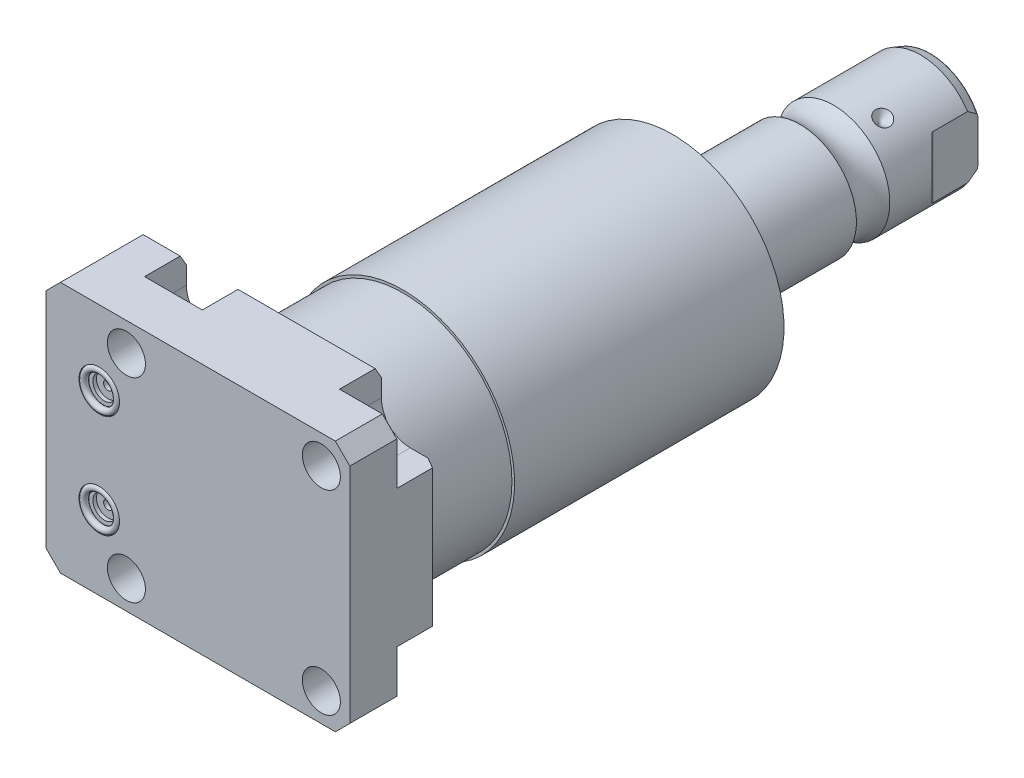
from build123d import *

# Parameters (mm, degrees)
SKETCH1_W                = 85.4964
SKETCH1_H                = 70.866
EXTRUDE1_DEPTH           = 25.019
SKETCH2_R                = 5.3594
CUT_EXTRUDE1_DEPTH       = 27.5209
LPATTERN1_COUNT          = 2
LPATTERN1_PITCH          = 54.864
LPATTERN1_COUNT_DIR2     = 2
LPATTERN1_PITCH_DIR2     = 54.864
CUT_EXTRUDE2_DEPTH       = 11.7856
SKETCH6_R                = 5.7023
CUT_EXTRUDE3_DEPTH       = 1.4478
SKETCH7_R                = 3.2512
CUT_EXTRUDE4_DEPTH       = 1.016
SKETCH8_R                = 1.2446
CUT_EXTRUDE5_DEPTH       = 11.9888
SKETCH9_R                = 0.9271
CHAMFER1_SIZE            = 4.064
CHAMFER2_SIZE            = 3.0226
CHAMFER2_SIZE2           = 1.745099
SKETCH14_R               = 31.3944
EXTRUDE2_DEPTH           = 104.5464
SKETCH15_OUTSIDE_W       = 121.686
SKETCH15_OUTSIDE_H       = 107.056
SKETCH15_OUTSIDE_R       = 30.6578
CUT_EXTRUDE9_DEPTH       = 25.4
CIRPATTERN1_COUNT        = 3
FILLET1_R                = 0.635
CUT_EXTRUDE12_DEPTH      = 36.433
CUT_EXTRUDE12_DEPTH_BACK = 36.433


with BuildPart() as part:
    # Sketch1 → Extrude1 (new body)
    with BuildSketch(Plane.XY):
        with Locations((-7.3152, 0)):
            Rectangle(SKETCH1_W, SKETCH1_H)
    extrude(amount=EXTRUDE1_DEPTH)

    # Sketch2 → Cut-Extrude1 (cut)
    with BuildSketch(Plane(origin=(0, 0, 0), x_dir=(-1, 0, 0), z_dir=(0, 0, -1))):
        with Locations((-27.432, -27.432)):
            Circle(SKETCH2_R)
    cut_extrude1 = extrude(amount=-CUT_EXTRUDE1_DEPTH, mode=Mode.SUBTRACT)

    # LPattern1: Cut-Extrude1 2 × 2
    with Locations(*[(-j * LPATTERN1_PITCH_DIR2, i * LPATTERN1_PITCH, 0) for i in range(LPATTERN1_COUNT) for j in range(LPATTERN1_COUNT_DIR2) if (i, j) != (0, 0)]):
        add(cut_extrude1, mode=Mode.SUBTRACT)

    # Sketch3 → Cut-Extrude2 (cut)
    with BuildSketch(Plane(origin=(0, 0, 0), x_dir=(-1, 0, 0), z_dir=(0, 0, -1))):
        with BuildLine():
            Line((-27.432, -19.304), (-35.433, -19.304))
            Line((-35.433, -19.304), (-35.433, -35.433))
            Line((-35.433, -35.433), (-19.304, -35.433))
            Line((-19.304, -35.433), (-19.304, -27.432))
            ThreePointArc((-19.304, -27.432), (-21.684636, -21.684636), (-27.432, -19.304))
        make_face()
        with BuildLine():
            Line((-35.433, 19.304), (-35.433, 35.433))
            Line((-35.433, 35.433), (-19.304, 35.433))
            Line((-19.304, 35.433), (-19.304, 27.432))
            ThreePointArc((-19.304, 27.432), (-21.684636, 21.684636), (-27.432, 19.304))
            Line((-27.432, 19.304), (-35.433, 19.304))
        make_face()
        with BuildLine():
            Line((19.304, 35.433), (19.304, 27.432))
            ThreePointArc((19.304, 27.432), (27.432, 19.304), (35.56, 27.432))
            Line((35.56, 27.432), (35.56, 35.433))
            Line((35.56, 35.433), (19.304, 35.433))
        make_face()
        with BuildLine():
            Line((35.56, -35.433), (19.304, -35.433))
            Line((19.304, -35.433), (19.304, -27.432))
            ThreePointArc((19.304, -27.432), (27.432, -19.304), (35.56, -27.432))
            Line((35.56, -27.432), (35.56, -35.433))
        make_face()
    extrude(amount=-CUT_EXTRUDE2_DEPTH, mode=Mode.SUBTRACT)

    # S2D0007 → Cut-Revolve1 (revolve, cut)
    with BuildSketch(Plane(origin=(-55.5498, -13.0048, 12.5222), x_dir=(0, 1, 0), z_dir=(0, 0, 1)), mode=Mode.PRIVATE) as cut_revolve1_sk:
        Polygon((0, -5.4864), (10.4775, -5.4864), (10.4775, -5.7404), (6.1849, -5.7404), (5.642307, -8.2931), (4.9784, -8.957007), (4.9784, -19.7104), (0, -19.7104), align=None)
    cut_revolve1 = revolve(cut_revolve1_sk.sketch.rotate(Axis((-35.077219, -13.0048, 12.5222), (-1, 0, 0)), 90), axis=Axis((-35.077219, -13.0048, 12.5222), (-1, 0, 0)), mode=Mode.SUBTRACT)  # turned: the seam where the file's is

    # Mirror1: Cut-Revolve1 across plane
    add(cut_revolve1.mirror(Plane.ZX), mode=Mode.SUBTRACT)

    # Sketch6 → Cut-Extrude3 (cut)
    with BuildSketch(Plane.XY.offset(25.019)):
        with Locations((-35.0774, -14.5288)):
            Circle(SKETCH6_R)
        with Locations((-35.0774, 14.5288)):
            Circle(SKETCH6_R)
    extrude(amount=-CUT_EXTRUDE3_DEPTH, mode=Mode.SUBTRACT)

    # Sketch7 → Cut-Extrude4 (cut)
    with BuildSketch(Plane.XY.offset(23.5712)):
        with Locations((-35.0774, 14.5288)):
            Circle(SKETCH7_R)
        with Locations((-35.0774, -14.5288)):
            Circle(SKETCH7_R)
    extrude(amount=-CUT_EXTRUDE4_DEPTH, mode=Mode.SUBTRACT)

    # Sketch8 → Cut-Extrude5 (cut)
    with BuildSketch(Plane.XY.offset(22.5552)):
        with Locations((-35.0774, 14.5288)):
            Circle(SKETCH8_R)
        with Locations((-35.0774, -14.5288)):
            Circle(SKETCH8_R)
    extrude(amount=-CUT_EXTRUDE5_DEPTH, mode=Mode.SUBTRACT)

    # Chamfer1
    chamfer1_edges = [part.edges().sort_by_distance(p)[0] for p in [
        (-50.0634, 35.433, 12.5095),
        (35.433, 35.433, 18.4023),
        (35.433, -35.433, 18.4023),
        (-50.0634, -35.433, 12.5095),
    ]]
    chamfer(chamfer1_edges, length=CHAMFER1_SIZE)

    # Chamfer2
    chamfer2_edges = [part.edges().sort_by_distance(p)[0] for p in [
        (-40.7797, -35.433, 0),
        (35.433, 0, 0),
        (0, 35.433, 0),
        (-40.7797, 35.433, 0),
        (0, -35.433, 0),
    ]]
    chamfer2_side = [part.faces().sort_by_distance(p)[0] for p in [
        (-8.721449, 0, 0),
    ]]
    chamfer(chamfer2_edges, length=CHAMFER2_SIZE, length2=CHAMFER2_SIZE2, reference=chamfer2_side[0])

    # Sketch14 → Extrude2 (add)
    with BuildSketch(Plane(origin=(0, 0, 0), x_dir=(-1, 0, 0), z_dir=(0, 0, -1))):
        with Locations(Location((0, 0, 0), (0, 0, 140.520961))):  # turned: the seam where the file's is
            Circle(SKETCH14_R)
    extrude(amount=EXTRUDE2_DEPTH)

    # Sketch15 outside → Cut-Extrude9 (cut)
    with BuildSketch(Plane(origin=(0, 0, 0), x_dir=(-1, 0, 0), z_dir=(0, 0, -1))):
        with Locations((7.315, 0)):
            Rectangle(SKETCH15_OUTSIDE_W, SKETCH15_OUTSIDE_H)
        Circle(SKETCH15_OUTSIDE_R, mode=Mode.SUBTRACT)
    extrude(amount=CUT_EXTRUDE9_DEPTH, mode=Mode.SUBTRACT)

    # Sketch16 → Cut-Revolve3 (revolve, cut)
    with BuildSketch(Plane(origin=(0, 0, 0), x_dir=(0, 0, 1), z_dir=(1, 0, 0)), mode=Mode.PRIVATE) as cut_revolve3_sk:
        Polygon((-104.5464, 19.05), (-101.238728, 31.3944), (-104.5464, 31.3944), align=None)
    revolve(cut_revolve3_sk.sketch.rotate(Axis((0, 0, -96.582204), (0, 0, 1)), 270), axis=Axis((0, 0, -96.582204), (0, 0, 1)), mode=Mode.SUBTRACT)  # turned: the seam where the file's is

    # Sketch17 → Revolve3 (revolve)
    with BuildSketch(Plane(origin=(0, 0, 0), x_dir=(0, 0, 1), z_dir=(1, 0, 0)), mode=Mode.PRIVATE) as revolve3_sk:
        with BuildLine():
            Line((-104.5464, 0), (-104.5464, 15.875))
            Line((-104.5464, 15.875), (-137.126506, 15.875))
            ThreePointArc((-137.126506, 15.875), (-141.8336, 14.3256), (-146.540694, 15.875))
            Line((-146.540694, 15.875), (-171.0182, 15.875))
            Line((-171.0182, 15.875), (-173.9392, 14.811843))
            Line((-173.9392, 14.811843), (-173.9392, 0))
            Line((-173.9392, 0), (-104.5464, 0))
        make_face()
    revolve(revolve3_sk.sketch.rotate(Axis((0, 0, -180.9369), (0, 0, 1)), 270), axis=Axis((0, 0, -180.9369), (0, 0, 1)))  # turned: the seam where the file's is

    # Sketch22 → Cut-Revolve4 (revolve, cut)
    with BuildSketch(Plane(origin=(0, 0, 0), x_dir=(1, 0, 0), z_dir=(0, 1, 0)), mode=Mode.PRIVATE) as cut_revolve4_sk:
        Polygon((-15.875, 154.9146), (-15.875, 152.5016), (-13.462, 152.5016), align=None)
    cut_revolve4 = revolve(cut_revolve4_sk.sketch.rotate(Axis((-21.668803, 0, -152.5016), (1, 0, 0)), 180), axis=Axis((-21.668803, 0, -152.5016), (1, 0, 0)), mode=Mode.SUBTRACT)  # turned: the seam where the file's is

    # CirPattern1: Cut-Revolve4 ×3 about axis
    cirpattern1_axis = Axis((0, 0, -180.9369), (0, 0, -1))
    for i in range(1, CIRPATTERN1_COUNT):
        add(cut_revolve4.rotate(cirpattern1_axis, i * 360 / CIRPATTERN1_COUNT), mode=Mode.SUBTRACT)

    # Fillet1
    fillet1_edges = [part.edges().sort_by_distance(p)[0] for p in [
        (14.811843, 0, -173.9392),
    ]]
    fillet(fillet1_edges, radius=FILLET1_R)

    # Sketch24 → Hole1 (revolve, cut)
    with BuildSketch(Plane(origin=(0, 0, -173.9392), x_dir=(0, 1, 0), z_dir=(1, 0, 0))):
        Polygon((0, 0), (0, 25.4), (6.9342, 21.233512), (6.9342, 0), align=None)
    revolve(axis=Axis((0, 0, -178.1834), (0, 0, 1)), mode=Mode.SUBTRACT)

    # Sketch26 → Cut-Extrude12 (cut, two sides)
    with BuildSketch(Plane(origin=(0, 0, 0), x_dir=(1, 0, 0), z_dir=(0, 1, 0))) as cut_extrude12_sk:
        with BuildLine():
            Line((-13.2842, 173.9392), (-13.2842, 161.2392))
            ThreePointArc((-13.2842, 161.2392), (-13.342204, 160.947595), (-13.507385, 160.700385))
            Line((-13.507385, 160.700385), (-15.875, 158.332769))
            Line((-15.875, 158.332769), (-15.875, 173.9392))
            Line((-15.875, 173.9392), (-13.2842, 173.9392))
        make_face()
        with BuildLine():
            Line((15.875, 173.9392), (13.2842, 173.9392))
            Line((13.2842, 173.9392), (13.2842, 161.2392))
            ThreePointArc((13.2842, 161.2392), (13.342204, 160.947595), (13.507385, 160.700385))
            Line((13.507385, 160.700385), (15.875, 158.332769))
            Line((15.875, 158.332769), (15.875, 173.9392))
        make_face()
    extrude(amount=CUT_EXTRUDE12_DEPTH, mode=Mode.SUBTRACT)
    extrude(cut_extrude12_sk.sketch, amount=-CUT_EXTRUDE12_DEPTH_BACK, mode=Mode.SUBTRACT)


with BuildPart() as body_2:
    # Sketch9 → Revolve1 (revolve)
    with BuildSketch(Plane(origin=(-41.656, -14.5288, 23.5712), x_dir=(1, 0, 0), z_dir=(0, 1, 0))):
        with Locations((11.3538, -0.9271)):
            Circle(SKETCH9_R)
    revolve(axis=Axis((-35.0774, -14.5288, 25.51811), (0, 0, -1)))


with BuildPart() as body_3:
    # Mirror2: mirrored copy
    add(body_2.part.mirror(Plane.ZX))


solid = Compound([part.part, body_2.part, body_3.part])
